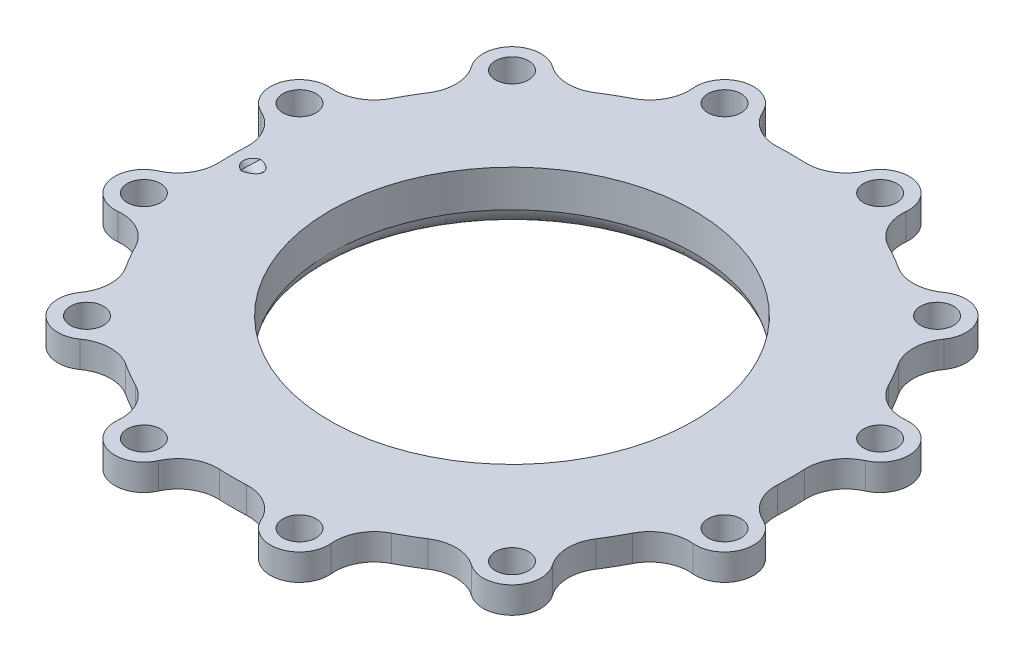
from build123d import *

# Parameters (mm, degrees)
FILLET1_R          = 1.27
HOLE2_D            = 8
CIRPATTERN2_COUNT  = 12
CUT_EXTRUDE1_DEPTH = 6.35
CIRPATTERN3_COUNT  = 12


with BuildPart() as part:
    # Sketch2 → Revolve1 (revolve)
    with BuildSketch(Plane.XY):
        with BuildLine():
            Line((43.84802, 12.7), (43.84802, 3.81))
            add(Edge.make_bspline(
                [(46.38802, 0), (44.388355655, 1.414157741), (43.84802, 3.81)],
                knots=[0, 0, 0, 1, 1, 1], degree=2))
            Line((46.38802, 0), (48.92802, 0))
            Line((48.92802, 0), (48.92802, 1.27))
            add(Edge.make_bspline(
                [(48.92802, 1.27), (48.92802, 2.362244726), (47.756086238, 4.78706255), (49.481317908, 8.0645), (50.19802, 8.0645)],
                knots=[0, 0, 0, 0, 0.567933924, 1, 1, 1, 1], degree=3))
            Line((50.19802, 8.0645), (59.72302, 8.0645))
            Line((59.72302, 8.0645), (59.72302, 6.35))
            Line((59.72302, 6.35), (79.375, 6.35))
            Line((79.375, 6.35), (79.375, 12.7))
            Line((79.375, 12.7), (43.84802, 12.7))
        make_face()
    revolve(axis=Axis((0, 45.051278076, 0), (0, -1, 0)))

    # Fillet1
    fillet1_edges = [part.edges().sort_by_distance(p)[0] for p in [
        (-59.72302, 8.0645, 0),
    ]]
    fillet(fillet1_edges, radius=FILLET1_R)

    # Sketch5 → Cut-Revolve2 (revolve, cut)
    with BuildSketch(Plane.XY):
        Polygon((-54.61, 6.35), (-55.388301154, 5.696927789), (-68.449745383, 21.262950873), (-66.406704853, 22.977265428), (-59.875982739, 15.194253886), (-59.875982739, 12.625753848), align=None)
    revolve(axis=Axis((-55.388301154, 5.696927789, 0), (-0.64278761, 0.766044443, 0)), mode=Mode.SUBTRACT)

    # Hole2 (through all)
    with Locations(Plane(origin=(0, 12.7, 0), x_dir=(1, 0, 0), z_dir=(0, 1, 0))):
        with Locations((-18.735910675, 69.923370565)):
            hole2 = Hole(HOLE2_D / 2)

    # CirPattern2: Hole2 ×12 about axis
    cirpattern2_axis = Axis((0, 0, 0), (0, 1, 0))
    for i in range(1, CIRPATTERN2_COUNT):
        add(hole2.rotate(cirpattern2_axis, i * 360 / CIRPATTERN2_COUNT), mode=Mode.SUBTRACT)

    # Sketch22 → Cut-Extrude1 (cut)
    with BuildSketch(Plane(origin=(0, 12.7, 0), x_dir=(1, 0, 0), z_dir=(0, 1, 0))):
        with BuildLine():
            ThreePointArc((76.670362462, -20.543761705), (76.23859227, -15.751249921), (72.809779145, -12.375181903))
            ThreePointArc((72.809779145, -12.375181903), (68.617057204, -8.666268439), (67.231849832, -3.242602068))
            ThreePointArc((67.231849832, -3.242602068), (67.31, 0), (67.231849832, 3.242602068))
            ThreePointArc((67.231849832, 3.242602068), (68.617057204, 8.666268439), (72.809779145, 12.375181903))
            ThreePointArc((72.809779145, 12.375181903), (76.23859227, 15.751249921), (76.670362462, 20.543761705))
            ThreePointArc((76.670362462, 20.543761705), (79.375, 0), (76.670362462, -20.543761705))
        make_face()
    cut_extrude1 = extrude(amount=-CUT_EXTRUDE1_DEPTH, mode=Mode.SUBTRACT)

    # CirPattern3: Cut-Extrude1 ×12 about axis
    cirpattern3_axis = Axis((0, 0, 0), (0, 1, 0))
    for i in range(1, CIRPATTERN3_COUNT):
        add(cut_extrude1.rotate(cirpattern3_axis, i * 360 / CIRPATTERN3_COUNT), mode=Mode.SUBTRACT)


solid = part.part
